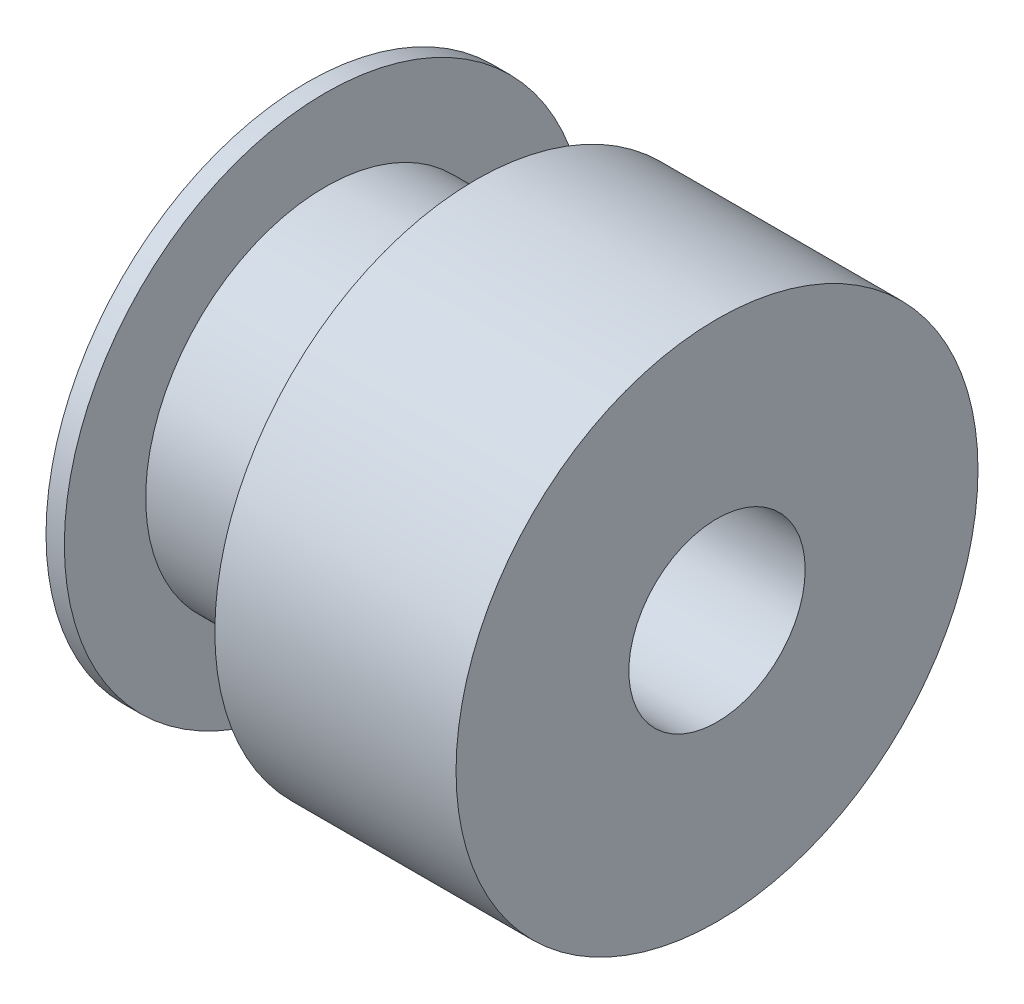
from build123d import *

# Parameters (mm, degrees)
SKETCH1_R           = 7.0485
BOSS_EXTRUDE1_DEPTH = 0.4953
SKETCH2_R           = 4.8514
BOSS_EXTRUDE2_DEPTH = 4.064
SKETCH3_R           = 7.0485
BOSS_EXTRUDE3_DEPTH = 0.4953
SKETCH4_R           = 7.0485
BOSS_EXTRUDE4_DEPTH = 6.0198
SKETCH5_R           = 2.38125
CUT_EXTRUDE1_DEPTH  = 12.0744


with BuildPart() as part:
    # Sketch1 → Boss-Extrude1 (new body)
    with BuildSketch(Plane(origin=(0, 0, 0), x_dir=(0, 0, -1), z_dir=(1, 0, 0))):
        Circle(SKETCH1_R)
    extrude(amount=BOSS_EXTRUDE1_DEPTH)

    # Sketch2 → Boss-Extrude2 (add)
    with BuildSketch(Plane(origin=(0.4953, 0, 0), x_dir=(0, 0, -1), z_dir=(1, 0, 0))):
        Circle(SKETCH2_R)
    extrude(amount=BOSS_EXTRUDE2_DEPTH)

    # Sketch3 → Boss-Extrude3 (add)
    with BuildSketch(Plane(origin=(4.5593, 0, 0), x_dir=(0, 0, -1), z_dir=(1, 0, 0))):
        Circle(SKETCH3_R)
    extrude(amount=BOSS_EXTRUDE3_DEPTH)

    # Sketch4 → Boss-Extrude4 (add)
    with BuildSketch(Plane(origin=(5.0546, 0, 0), x_dir=(0, 0, -1), z_dir=(1, 0, 0))):
        Circle(SKETCH4_R)
    extrude(amount=BOSS_EXTRUDE4_DEPTH)

    # Sketch5 → Cut-Extrude1 (cut, through all)
    with BuildSketch(Plane(origin=(11.0744, 0, 0), x_dir=(0, 0, -1), z_dir=(1, 0, 0))):
        Circle(SKETCH5_R)
    extrude(amount=-CUT_EXTRUDE1_DEPTH, mode=Mode.SUBTRACT)


solid = part.part
